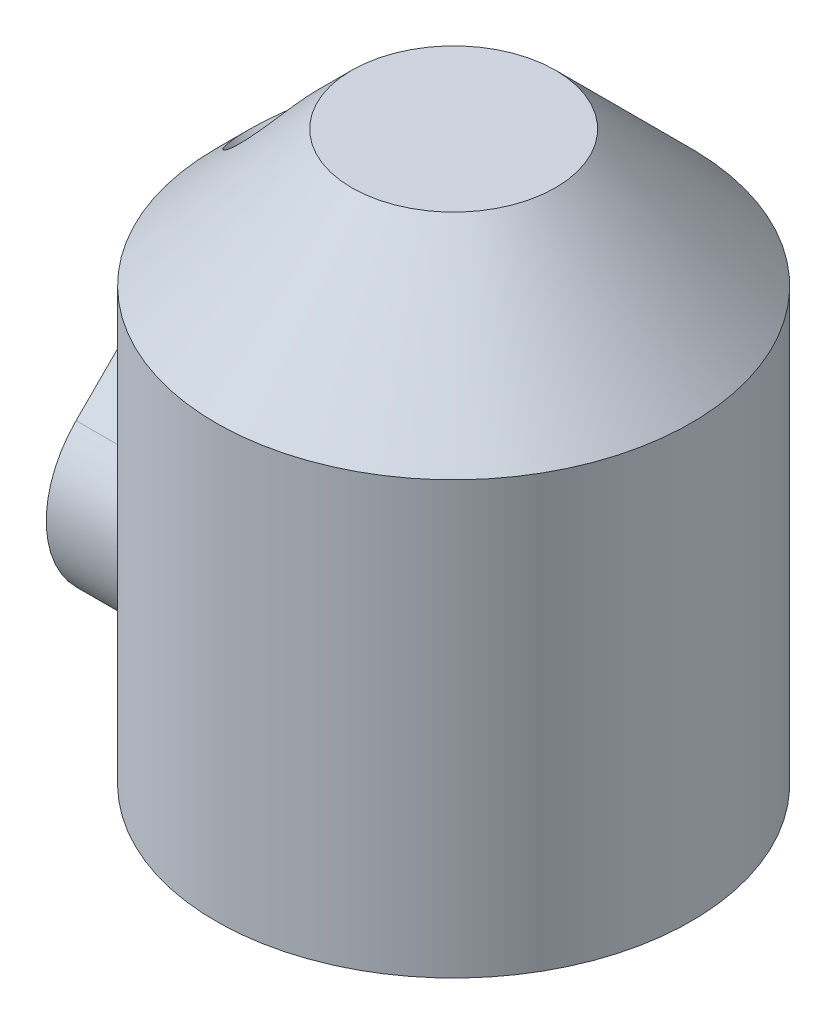
from build123d import *

# Parameters (mm, degrees)
BOSS_EXTRUDE1_DEPTH                  = 6.35
BOSS_EXTRUDE1_DIRECTION_2_REACH      = 77.385
BOSS_EXTRUDE1_DIRECTION_2_END_RADIUS = 22.225
CUT_EXTRUDE1_DEPTH                   = 68.524459612
CUT_EXTRUDE2_REACH                   = 69.258
CIRPATTERN1_COUNT                    = 6


with BuildPart() as part:
    # Sketch1 → Revolve1 (revolve)
    with BuildSketch(Plane.XY):
        Polygon((0, 0), (0, -29.68625), (-3.81, -33.49625), (-3.81, -44.92625), (-2.54, -46.19625), (-2.54, -48.73625), (-3.33375, -48.73625), (-3.33375, -46.525032015), (-4.60375, -45.255032015), (-4.60375, -40.708134797), (-5.527675, -39.784209797), (-6.4516, -40.708134797), (-6.4516, -47.058134797), (-4.445, -49.064734797), (-4.445, -56.684734797), (-6.0325, -56.684734797), (-6.0325, -49.722298828), (-8.0391, -47.715698828), (-17.00813597, -56.684734797), (-20.6375, -53.055370767), (-22.225, -53.055370767), (-22.225, -12.7), (-9.525, 0), align=None)
        Polygon((-5.3975, -32.83868597), (-1.5875, -29.02868597), (-1.5875, -6.35), (-19.05, -23.8125), (-5.3975, -37.465), align=None, mode=Mode.SUBTRACT)
        Polygon((-8.0391, -45.470634797), (-8.0391, -40.050570767), (-6.548046632, -38.559517399), (-15.875, -29.23256403), (-19.05, -32.40756403), (-19.05, -52.397806737), (-17.00813597, -54.439670767), align=None, mode=Mode.SUBTRACT)
    revolve(axis=Axis((0, -29.68625, 0), (0, -1, 0)))

    # Sketch2 → Boss-Extrude1 (add)
    with BuildSketch(Plane.ZY.offset(22.225)):
        with BuildLine():
            Line((-6.735192091, -34.539807909), (-0.79375, -28.598365818))
            Line((-0.79375, -28.598365818), (-0.79375, -15.898365818))
            Line((-0.79375, -15.898365818), (0.79375, -15.898365818))
            Line((0.79375, -15.898365818), (0.79375, -28.598365818))
            Line((0.79375, -28.598365818), (6.735192091, -34.539807909))
            ThreePointArc((6.735192091, -34.539807909), (0, -50.8), (-6.735192091, -34.539807909))
        make_face()
    extrude(amount=BOSS_EXTRUDE1_DEPTH)

    # Boss-Extrude1 direction 2: up to this cylinder (the profile starts outside it)
    boss_extrude1_direction_2_end = Plane(origin=(0, -39.487688, 0), z_dir=(0, 1, 0)) * Cylinder(BOSS_EXTRUDE1_DIRECTION_2_END_RADIUS, 200.22, mode=Mode.PRIVATE)
    # Sketch2 → Boss-Extrude1 direction 2 (add, up to the surface)
    with BuildSketch(Plane.ZY.offset(22.225), mode=Mode.PRIVATE) as boss_extrude1_direction_2_sk1:
        with BuildLine():
            Line((-6.735192091, -34.539807909), (-0.79375, -28.598365818))
            Line((-0.79375, -28.598365818), (-0.79375, -15.898365818))
            Line((-0.79375, -15.898365818), (0.79375, -15.898365818))
            Line((0.79375, -15.898365818), (0.79375, -28.598365818))
            Line((0.79375, -28.598365818), (6.735192091, -34.539807909))
            ThreePointArc((6.735192091, -34.539807909), (0, -50.8), (-6.735192091, -34.539807909))
        make_face()
    boss_extrude1_direction_2_tool1 = extrude(boss_extrude1_direction_2_sk1.sketch, amount=-BOSS_EXTRUDE1_DIRECTION_2_REACH, mode=Mode.PRIVATE) - boss_extrude1_direction_2_end
    add(boss_extrude1_direction_2_tool1.solids().sort_by_distance((-22.225, -39.487688, 0))[0])
    add(boss_extrude1_direction_2_tool1.solids().sort_by_distance((-22.225, -39.487688, 0))[1])

    # Sketch3 → Cut-Extrude1 (cut, through all)
    with BuildSketch(Plane(origin=(0, 0, -0.79375), x_dir=(-1, 0, 0), z_dir=(0, 0, -1))):
        Polygon((28.575, -28.598365818), (22.21082137, -15.898365818), (28.575, -15.898365818), align=None)
    extrude(amount=-CUT_EXTRUDE1_DEPTH, mode=Mode.SUBTRACT)

    # Sketch4 → Cut-Extrude2 (cut, up to next)
    with BuildSketch(Plane.XY, mode=Mode.PRIVATE) as cut_extrude2_sk1:
        with BuildLine():
            Line((-3.2258, -33.49625), (-3.638891782, -33.909341782))
            ThreePointArc((-3.638891782, -33.909341782), (-3.2258, -34.906633563), (-2.812708218, -33.909341782))
            Line((-2.812708218, -33.909341782), (-3.2258, -33.49625))
        make_face()
    cut_extrude2_tool1 = extrude(cut_extrude2_sk1.sketch, amount=-CUT_EXTRUDE2_REACH, mode=Mode.PRIVATE) & part.part
    # Sketch4 → Cut-Extrude2 (cut, up to next)
    with BuildSketch(Plane.XY, mode=Mode.PRIVATE) as cut_extrude2_sk2:
        with BuildLine():
            Line((-5.5626, -40.708134797), (-6.191217928, -41.336752726))
            ThreePointArc((-6.191217928, -41.336752726), (-5.5626, -42.854370654), (-4.933982072, -41.336752726))
            Line((-4.933982072, -41.336752726), (-5.5626, -40.708134797))
        make_face()
    cut_extrude2_tool2 = extrude(cut_extrude2_sk2.sketch, amount=-CUT_EXTRUDE2_REACH, mode=Mode.PRIVATE) & part.part
    cut_extrude2_1 = cut_extrude2_tool1.solids().sort_by_distance((-3.2258, -34.281406, 0))[0]
    add(cut_extrude2_1, mode=Mode.SUBTRACT)
    cut_extrude2_2 = cut_extrude2_tool2.solids().sort_by_distance((-5.5626, -41.902937, 0))[0]
    add(cut_extrude2_2, mode=Mode.SUBTRACT)
    cut_extrude2 = cut_extrude2_1 + cut_extrude2_2  # Cut-Extrude2 as one shape, for the pattern or mirror that repeats it

    # CirPattern1: Cut-Extrude2 ×6 about axis
    cirpattern1_axis = Axis((0, -29.68625, 0), (0, -1, 0))
    for i in range(1, CIRPATTERN1_COUNT):
        add(cut_extrude2.rotate(cirpattern1_axis, i * 360 / CIRPATTERN1_COUNT), mode=Mode.SUBTRACT)

    # Sketch6 → 1_8 NPT Tapped Hole1 (revolve, cut)
    with BuildSketch(Plane(origin=(-28.575, -41.275, 0), x_dir=(0, 0, 1), z_dir=(0, 1, 0))):
        Polygon((0, 0), (0, 14.217468714), (4.2164, 11.684), (4.2164, 6.858), (4.537401096, 6.858), (4.7427388, 0), align=None)
    revolve(axis=Axis((-34.925, -41.275, 0), (1, 0, 0)), mode=Mode.SUBTRACT)

    # Sketch10 → 1_8 NPT Tapped Hole3 (revolve, cut)
    with BuildSketch(Plane(origin=(-15.987820151, -6.462820151, 0), x_dir=(-0.707106781186546, -0.707106781186549, 0), z_dir=(0, 0, 1))):
        Polygon((0, 0), (0, 14.217468714), (4.2164, 11.684), (4.2164, 6.858), (4.537401096, 6.858), (4.7427388, 0), align=None)
    revolve(axis=Axis((-20.477948212, -1.972692091, 0), (0.707106781186549, -0.707106781186546, 0)), mode=Mode.SUBTRACT)


solid = part.part
